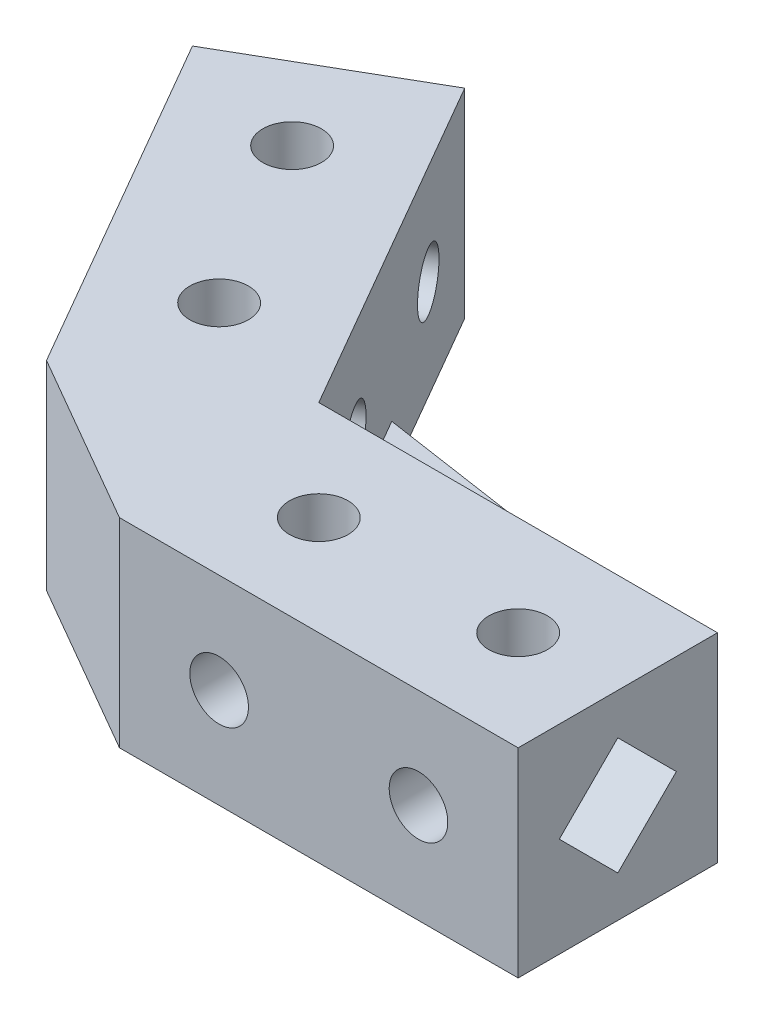
from build123d import *

# Parameters (mm, degrees)
SKETCH1_W           = 34
SKETCH1_H           = 17
SKETCH1_R           = 2.5
BOSS_EXTRUDE1_DEPTH = 17
SKETCH6_OUTSIDE_W   = 44.328
SKETCH6_OUTSIDE_H   = 27.328
SKETCH6_OUTSIDE_W_2 = 34
SKETCH6_OUTSIDE_H_2 = 17
SKETCH6_OUTSIDE_R   = 2.5
CUT_EXTRUDE10_DEPTH = 18
SKETCH7_OUTSIDE_W   = 27.328
SKETCH7_OUTSIDE_H   = 27.328
SKETCH7_OUTSIDE_W_2 = 17
SKETCH7_OUTSIDE_H_2 = 17
CUT_EXTRUDE11_DEPTH = 17
BOSS_EXTRUDE2_DEPTH = 17
SKETCH13_R          = 2.5
BOSS_EXTRUDE3_DEPTH = 4


with BuildPart() as part:
    # sketch1 → Boss-Extrude1 (new body)
    with BuildSketch(Plane(origin=(0, 0, 0), x_dir=(1, 0, 0), z_dir=(0, 1, 0))):
        with Locations((17, -8.5)):
            Rectangle(SKETCH1_W, SKETCH1_H)
        with Locations((8.5, -8.5)):
            Circle(SKETCH1_R, mode=Mode.SUBTRACT)
        with Locations((25.5, -8.5)):
            Circle(SKETCH1_R, mode=Mode.SUBTRACT)
    extrude(amount=BOSS_EXTRUDE1_DEPTH)

    # Sketch6 outside → Cut-Extrude10 (cut, through all)
    with BuildSketch(Plane(origin=(0, 0, 0), x_dir=(-1, 0, 0), z_dir=(0, 0, -1))):
        with Locations((-17, 8.5)):
            Rectangle(SKETCH6_OUTSIDE_W, SKETCH6_OUTSIDE_H)
        with Locations((-17, 8.5)):
            Rectangle(SKETCH6_OUTSIDE_W_2, SKETCH6_OUTSIDE_H_2, mode=Mode.SUBTRACT)
        with Locations((-25.5, 8.5)):
            Circle(SKETCH6_OUTSIDE_R)
        with Locations((-8.5, 8.5)):
            Circle(SKETCH6_OUTSIDE_R)
    extrude(amount=-CUT_EXTRUDE10_DEPTH, mode=Mode.SUBTRACT)

    # Sketch7 outside → Cut-Extrude11 (cut)
    with BuildSketch(Plane(origin=(34, 0, 0), x_dir=(0, 0, -1), z_dir=(1, 0, 0))):
        with Locations((-8.5, 8.5)):
            Rectangle(SKETCH7_OUTSIDE_W, SKETCH7_OUTSIDE_H)
        with Locations((-8.5, 8.5)):
            Rectangle(SKETCH7_OUTSIDE_W_2, SKETCH7_OUTSIDE_H_2, mode=Mode.SUBTRACT)
        Polygon((-8.5, 13.492173875), (-3.507826125, 8.5), (-8.5, 3.507826125), (-13.492173875, 8.5), align=None)
    extrude(amount=-CUT_EXTRUDE11_DEPTH, mode=Mode.SUBTRACT)


with BuildPart() as body_2:
    # Mirror6: mirrored copy
    add(part.part.mirror(Plane(origin=(0, 0, 0), x_dir=(-0.5, 0, 0.866025404), z_dir=(-0.866025404, 0, -0.5))))


with BuildPart() as part_1:
    add(part.part)

    add(body_2.part)  # Boss-Extrude2 merges body 2
    # Sketch11 → Boss-Extrude2 (add)
    with BuildSketch(Plane(origin=(0, 0, 0), x_dir=(1, 0, 0), z_dir=(0, 1, 0))):
        Polygon((-14.722431864, -8.5), (0, -17), (0, 0), align=None)
    extrude(amount=BOSS_EXTRUDE2_DEPTH)

    # Sketch13 → Boss-Extrude3 (add)
    with BuildSketch(Plane(origin=(0, 0, 0), x_dir=(1, 0, 0), z_dir=(0, 1, 0))):
        Polygon((7.152847248, 12.389094852), (-8.5, 14.722431864), (0, 0), (17, 0), align=None)
        with Locations((4.652847248, 8.058967833)):
            Circle(SKETCH13_R, mode=Mode.SUBTRACT)
    extrude(amount=BOSS_EXTRUDE3_DEPTH)


solid = part_1.part
